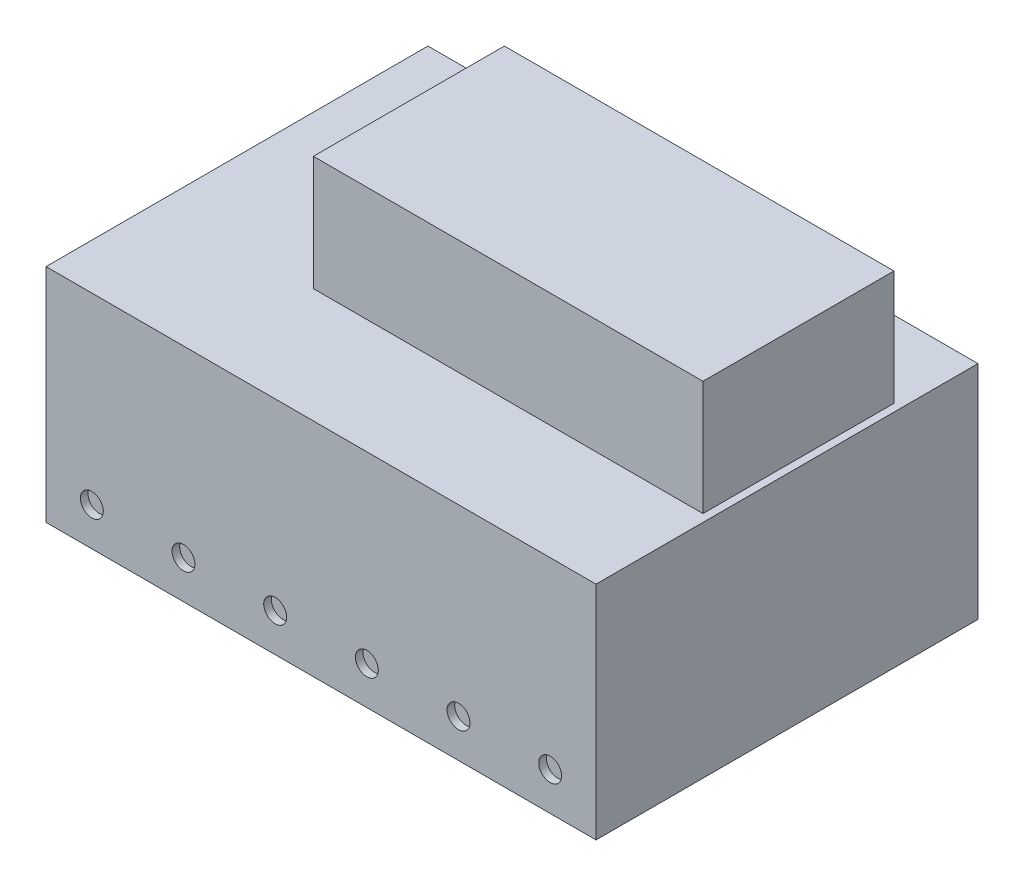
from build123d import *

# Parameters (mm, degrees)
SKETCH1_W               = 72
SKETCH1_H               = 29
BOSS_EXTRUDE1_DEPTH     = 50
SKETCH3_R               = 2.5
SKETCH3_W               = 51
SKETCH3_H               = 25
BOSS_EXTRUDE3_DEPTH     = 15
SKETCH2_R               = 1.5
CUT_EXTRUDE1_DEPTH      = 1
SKETCH4_R               = 2.5
CUT_EXTRUDE2_DEPTH      = 40
CUT_EXTRUDE2_DEPTH_BACK = 40


with BuildPart() as part:
    # Sketch1 → Boss-Extrude1 (new body)
    with BuildSketch(Plane.XY):
        Rectangle(SKETCH1_W, SKETCH1_H)
    extrude(amount=BOSS_EXTRUDE1_DEPTH)

    # Sketch3 → Boss-Extrude3 (add)
    with BuildSketch(Plane(origin=(0, 14.5, 0), x_dir=(1, 0, 0), z_dir=(0, 1, 0))):
        with Locations((-26, -5)):
            Circle(SKETCH3_R)
        with Locations((26, -5)):
            Circle(SKETCH3_R)
        with Locations((9.5, -22.5)):
            Rectangle(SKETCH3_W, SKETCH3_H)
    extrude(amount=BOSS_EXTRUDE3_DEPTH)

    # Sketch2 → Cut-Extrude1 (cut)
    with BuildSketch(Plane.XY.offset(50)):
        with Locations((-30, -9.5)):
            Circle(SKETCH2_R)
        with Locations((-18, -9.5)):
            Circle(SKETCH2_R)
        with Locations((-6, -9.5)):
            Circle(SKETCH2_R)
        with Locations((6, -9.5)):
            Circle(SKETCH2_R)
        with Locations((18, -9.5)):
            Circle(SKETCH2_R)
        with Locations((30, -9.5)):
            Circle(SKETCH2_R)
    extrude(amount=-CUT_EXTRUDE1_DEPTH, mode=Mode.SUBTRACT)

    # Sketch4 → Cut-Extrude2 (cut, two sides)
    with BuildSketch(Plane(origin=(0, 14.5, 0), x_dir=(1, 0, 0), z_dir=(0, 1, 0))) as cut_extrude2_sk:
        with Locations((26, -5)):
            Circle(SKETCH4_R)
        with Locations((-26, -5)):
            Circle(SKETCH4_R)
    extrude(amount=CUT_EXTRUDE2_DEPTH, mode=Mode.SUBTRACT)
    extrude(cut_extrude2_sk.sketch, amount=-CUT_EXTRUDE2_DEPTH_BACK, mode=Mode.SUBTRACT)


solid = part.part
